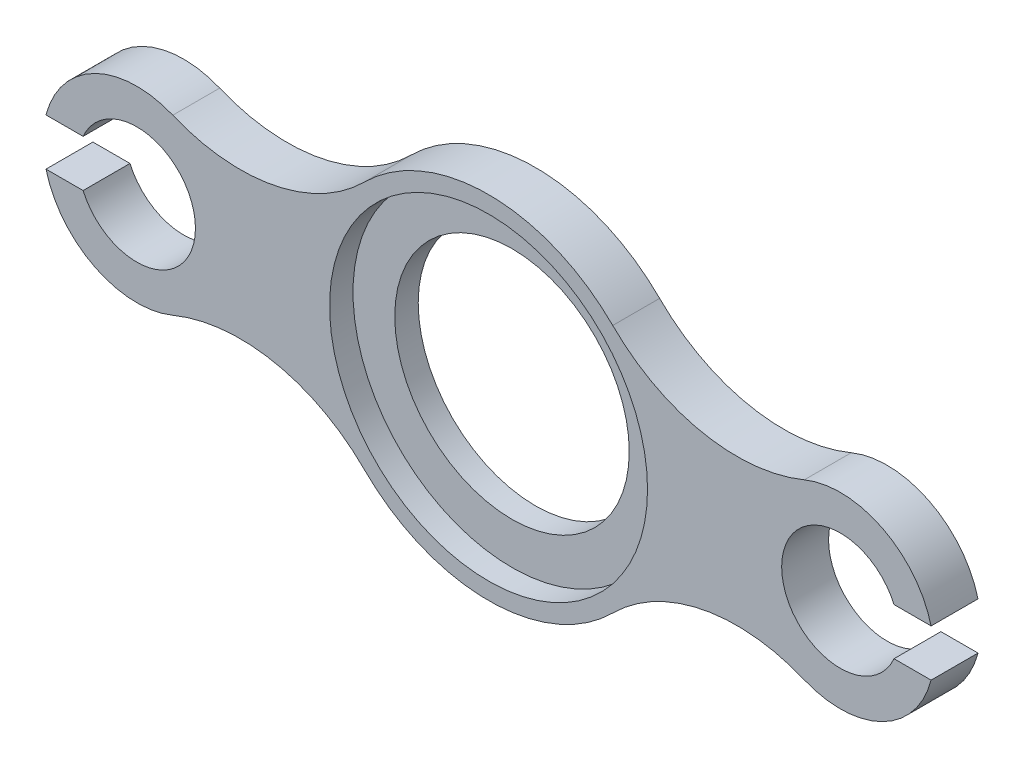
from build123d import *

# Parameters (mm, degrees)
ESQUISSE1_R        = 67.8
BOSS_EXTRU_1_DEPTH = 20
ESQUISSE1_4_R      = 67.8
ESQUISSE1_4_R_2    = 50
BOSS_EXTRU_2_DEPTH = 10


with BuildPart() as part:
    # Esquisse1 → Boss.-Extru.1 (new body)
    with BuildSketch(Plane.XY):
        with BuildLine():
            Line((-188.729833462, 10), (-172.912878475, 10))
            ThreePointArc((-172.912878475, 10), (-125, 0), (-172.912878475, -10))
            Line((-172.912878475, -10), (-188.729833462, -10))
            ThreePointArc((-188.729833462, -10), (-167.842344673, -35.800149952), (-134.666666667, -36.944402673))
            ThreePointArc((-134.666666667, -36.944402673), (-91.362529225, -32.640861336), (-52.958333333, -53.107578843))
            ThreePointArc((-52.958333333, -53.107578843), (0, -75), (52.958333333, -53.107578843))
            ThreePointArc((52.958333333, -53.107578843), (91.362529225, -32.640861336), (134.666666667, -36.944402673))
            ThreePointArc((134.666666667, -36.944402673), (167.842344673, -35.800149952), (188.729833462, -10))
            Line((188.729833462, -10), (172.912878475, -10))
            ThreePointArc((172.912878475, -10), (125, 0), (172.912878475, 10))
            Line((172.912878475, 10), (188.729833462, 10))
            ThreePointArc((188.729833462, 10), (167.842344673, 35.800149952), (134.666666667, 36.944402673))
            ThreePointArc((134.666666667, 36.944402673), (91.362529225, 32.640861336), (52.958333333, 53.107578843))
            ThreePointArc((52.958333333, 53.107578843), (0, 75), (-52.958333333, 53.107578843))
            ThreePointArc((-52.958333333, 53.107578843), (-91.362529225, 32.640861336), (-134.666666667, 36.944402673))
            ThreePointArc((-134.666666667, 36.944402673), (-167.842344673, 35.800149952), (-188.729833462, 10))
        make_face()
        Circle(ESQUISSE1_R, mode=Mode.SUBTRACT)
    extrude(amount=BOSS_EXTRU_1_DEPTH)

    # Esquisse1_4 → Boss.-Extru.2 (add)
    with BuildSketch(Plane.XY):
        Circle(ESQUISSE1_4_R)
        Circle(ESQUISSE1_4_R_2, mode=Mode.SUBTRACT)
    extrude(amount=BOSS_EXTRU_2_DEPTH)


solid = part.part
